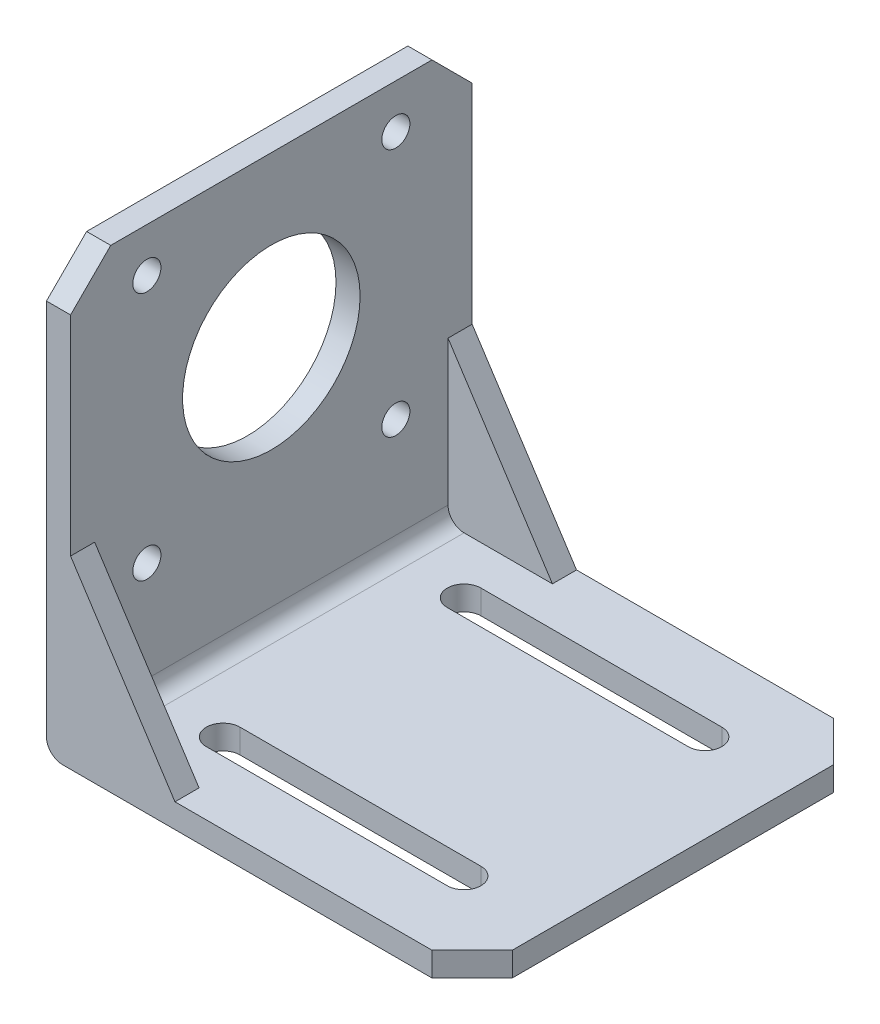
from build123d import *

# Parameters (mm, degrees)
SKETCH_1_W              = 53
SKETCH_1_H              = 50
EXTRUDE_1_DEPTH         = 3
CHAMFER_1_SIZE          = 5
CUT_EXTRUDE_1_REACH     = 38.555
SKETCH_3_W              = 3
SKETCH_3_H              = 50
EXTRUDE_2_DEPTH         = 51
FILLET_1_R              = 2
RIB_1_REACH             = 80.219
SKETCH_6_WALL_W         = 182.292207198
SKETCH_6_WALL_H         = 3
RIB_3_REACH             = 80.219
SKETCH_8_WALL_W         = 182.292207198
SKETCH_8_WALL_H         = 3
CHAMFER_2_SIZE          = 5
CUT_EXTRUDE_2_REACH     = 79.724
SKETCH_9_R              = 11.05
HOLE_WIZARD_3_5_3_5_1_D = 3.5


with BuildPart() as part:
    # 草图1 → 凸台-拉伸1 (new body)
    with BuildSketch(Plane(origin=(0, 0, 0), x_dir=(1, 0, 0), z_dir=(0, 1, 0))):
        Rectangle(SKETCH_1_W, SKETCH_1_H)
    extrude(amount=EXTRUDE_1_DEPTH)

    # 倒角1
    chamfer_1_edges = [part.edges().sort_by_distance(p)[0] for p in [
        (26.5, 1.5, 25),
        (26.5, 1.5, -25),
    ]]
    chamfer(chamfer_1_edges, length=CHAMFER_1_SIZE)

    # 草图2 → 切除-拉伸1 (cut, up to next)
    with BuildSketch(Plane(origin=(0, 3, 0), x_dir=(1, 0, 0), z_dir=(0, 1, 0)), mode=Mode.PRIVATE) as cut_extrude_1_sk1:
        with BuildLine():
            Line((-14.5, 17.1), (15.5, 17.1))
            ThreePointArc((15.5, 17.1), (17.6, 15), (15.5, 12.9))
            Line((15.5, 12.9), (-14.5, 12.9))
            ThreePointArc((-14.5, 12.9), (-16.6, 15), (-14.5, 17.1))
        make_face()
    cut_extrude_1_tool1 = extrude(cut_extrude_1_sk1.sketch, amount=-CUT_EXTRUDE_1_REACH, mode=Mode.PRIVATE) & part.part
    # 草图2 → 切除-拉伸1 (cut, up to next)
    with BuildSketch(Plane(origin=(0, 3, 0), x_dir=(1, 0, 0), z_dir=(0, 1, 0)), mode=Mode.PRIVATE) as cut_extrude_1_sk2:
        with BuildLine():
            Line((-14.5, -12.9), (15.5, -12.9))
            ThreePointArc((15.5, -12.9), (17.6, -15), (15.5, -17.1))
            Line((15.5, -17.1), (-14.5, -17.1))
            ThreePointArc((-14.5, -17.1), (-16.6, -15), (-14.5, -12.9))
        make_face()
    cut_extrude_1_tool2 = extrude(cut_extrude_1_sk2.sketch, amount=-CUT_EXTRUDE_1_REACH, mode=Mode.PRIVATE) & part.part
    add(cut_extrude_1_tool1.solids().sort_by_distance((0.5, 3, -15))[0], mode=Mode.SUBTRACT)
    add(cut_extrude_1_tool2.solids().sort_by_distance((0.5, 3, 15))[0], mode=Mode.SUBTRACT)

    # 草图3 → 凸台-拉伸2 (add)
    with BuildSketch(Plane(origin=(0, 3, 0), x_dir=(1, 0, 0), z_dir=(0, 1, 0))):
        with Locations((-25, 0)):
            Rectangle(SKETCH_3_W, SKETCH_3_H)
    extrude(amount=EXTRUDE_2_DEPTH)

    # 圆角1
    fillet_1_edges = [part.edges().sort_by_distance(p)[0] for p in [
        (-26.5, 0, 0),
        (-23.5, 3, 0),
    ]]
    fillet(fillet_1_edges, radius=FILLET_1_R)

    # 草图6 wall → 筋1 (add, up to next)
    with BuildSketch(Plane(origin=(-17, 13, 25), x_dir=(0.544988350595, -0.838443616301, 0), z_dir=(0.838443616301, 0.544988350595, 0)), mode=Mode.PRIVATE) as rib_1_sk1:
        with Locations((0, 1.5)):
            Rectangle(SKETCH_6_WALL_W, SKETCH_6_WALL_H)
    rib_1_tool1 = extrude(rib_1_sk1.sketch, amount=-RIB_1_REACH, mode=Mode.PRIVATE) - part.part
    add(rib_1_tool1.solids().sort_by_distance((-17, 13, 25))[0])

    # 草图8 wall → 筋3 (add, up to next)
    with BuildSketch(Plane(origin=(-17, 13, -25), x_dir=(-0.544988350595, 0.838443616301, 0), z_dir=(0.838443616301, 0.544988350595, 0)), mode=Mode.PRIVATE) as rib_3_sk1:
        with Locations((0, 1.5)):
            Rectangle(SKETCH_8_WALL_W, SKETCH_8_WALL_H)
    rib_3_tool1 = extrude(rib_3_sk1.sketch, amount=-RIB_3_REACH, mode=Mode.PRIVATE) - part.part
    add(rib_3_tool1.solids().sort_by_distance((-17, 13, -25))[0])

    # 倒角2
    chamfer_2_edges = [part.edges().sort_by_distance(p)[0] for p in [
        (-25, 54, 25),
        (-25, 54, -25),
    ]]
    chamfer(chamfer_2_edges, length=CHAMFER_2_SIZE)

    # 草图9 → 切除-拉伸2 (cut, up to next)
    with BuildSketch(Plane(origin=(-23.5, 0, 0), x_dir=(0, 0, -1), z_dir=(1, 0, 0)), mode=Mode.PRIVATE) as cut_extrude_2_sk1:
        with Locations((0, 33)):
            Circle(SKETCH_9_R)
    cut_extrude_2_tool1 = extrude(cut_extrude_2_sk1.sketch, amount=-CUT_EXTRUDE_2_REACH, mode=Mode.PRIVATE) & part.part
    add(cut_extrude_2_tool1.solids().sort_by_distance((-23.5, 33, 0))[0], mode=Mode.SUBTRACT)

    # Ø3.5 (3.5) 直径孔1 (through all)
    with Locations(Plane(origin=(-23.5, 0, 0), x_dir=(0, 0, -1), z_dir=(1, 0, 0))):
        with Locations((-15.5, 48.5), (-15.5, 17.5), (15.5, 17.5), (15.5, 48.5)):
            Hole(HOLE_WIZARD_3_5_3_5_1_D / 2)


solid = part.part
